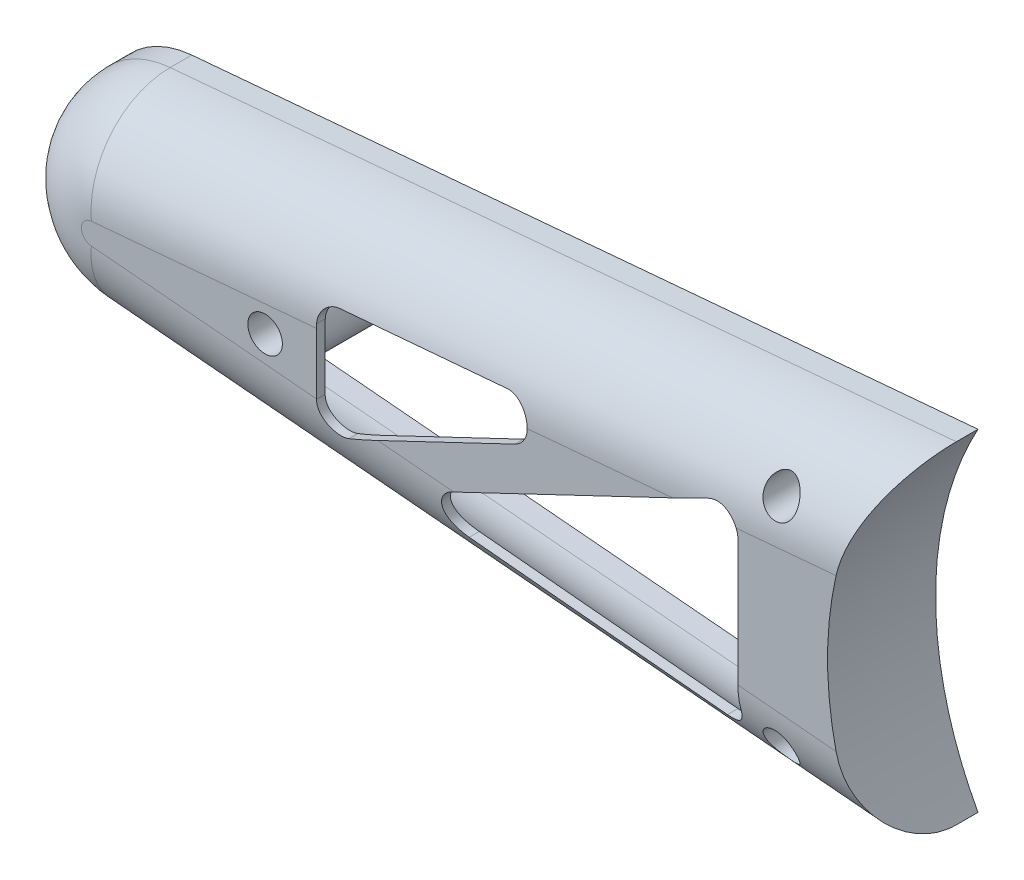
from build123d import *

# Parameters (mm, degrees)
BOSS_EXTRUDE1_DEPTH             = 25
BOSS_EXTRUDE1_DEPTH_BACK        = 25
FILLET1_R                       = 20
SHELL1_T                        = 2
CUT_EXTRUDE1_DEPTH              = 154.948043209
BOSS_EXTRUDE2_REACH             = 149.733
SKETCH4_R                       = 7.5
BOSS_EXTRUDE2_DIRECTION_2_REACH = 149.733
CUT_EXTRUDE2_DEPTH              = 148.732867071
CUT_EXTRUDE2_DEPTH_BACK         = 148.732867071
SKETCH5_R                       = 1.75
SKETCH6_R                       = 4
CUT_EXTRUDE3_DEPTH              = 12
CHAMFER1_SIZE                   = 2
SKETCH7_W                       = 361.368008509
SKETCH7_H                       = 191.328530185
CUT_EXTRUDE4_DEPTH              = 148.732867071
CUT_EXTRUDE5_DEPTH              = 148.732867071
BOSS_EXTRUDE3_REACH             = 132.788


with BuildPart() as part:
    # Sketch1 → Boss-Extrude1 (new, two sides: drawn at the far end of the back side and taken through both)
    with BuildSketch(Plane.XY.offset(-BOSS_EXTRUDE1_DEPTH_BACK)):
        with BuildLine():
            Line((-101.96875, 22.41370169), (96.5, 39.846580782))
            ThreePointArc((96.5, 39.846580782), (140, 0), (96.5, -39.846580782))
            Line((96.5, -39.846580782), (-101.96875, -22.41370169))
            ThreePointArc((-101.96875, -22.41370169), (-122.5, 0), (-101.96875, 22.41370169))
        make_face()
    extrude(amount=BOSS_EXTRUDE1_DEPTH + BOSS_EXTRUDE1_DEPTH_BACK)

    # Fillet1
    fillet1_edges = [part.edges().sort_by_distance(p)[0] for p in [
        (-2.734375, -31.130141236, -25),
        (140, 0, -25),
        (-2.734375, 31.130141236, -25),
        (-122.5, 0, -25),
        (-2.734375, 31.130141236, 25),
        (140, 0, 25),
        (-2.734375, -31.130141236, 25),
        (-122.5, 0, 25),
    ]]
    fillet(fillet1_edges, radius=FILLET1_R)

    # Shell1 (no face opened: a closed hollow body)
    add(offset(amount=-SHELL1_T, mode=Mode.PRIVATE), mode=Mode.SUBTRACT)

    # Sketch2 → Cut-Extrude1 (cut, through all)
    with BuildSketch(Plane.XY.offset(25)):
        with BuildLine():
            Line((49.437173226, 13.583043514), (49.437173226, -20.924247919))
            ThreePointArc((49.437173226, -20.924247919), (47.779211905, -24.643223244), (43.904862239, -25.895831672))
            Line((43.904862239, -25.895831672), (-15.19932205, -19.567504869))
            ThreePointArc((-15.19932205, -19.567504869), (-19.595683588, -15.437459669), (-16.818802271, -10.082630233))
            Line((-16.818802271, -10.082630233), (42.285382017, 18.096334397))
            ThreePointArc((42.285382017, 18.096334397), (47.105603847, 17.811456695), (49.437173226, 13.583043514))
        make_face()
        with BuildLine():
            Line((-2.180462074, 6.820738981), (-40.945374431, -11.661118224))
            ThreePointArc((-40.945374431, -11.661118224), (-45.765596261, -11.376240521), (-48.09716564, -7.147827341))
            Line((-48.09716564, -7.147827341), (-48.09716564, 7.992291845))
            ThreePointArc((-48.09716564, 7.992291845), (-46.781400109, 11.372590113), (-43.526599088, 12.973816402))
            Line((-43.526599088, 12.973816402), (-4.761686731, 16.315554421))
            ThreePointArc((-4.761686731, 16.315554421), (0.492631081, 12.6457047), (-2.180462074, 6.820738981))
        make_face()
    extrude(amount=-CUT_EXTRUDE1_DEPTH, mode=Mode.SUBTRACT)

    # Sketch4 → Boss-Extrude2 (add, up to next)
    with BuildSketch(Plane.XY, mode=Mode.PRIVATE) as boss_extrude2_sk1:
        with Locations((-60, 0)):
            Circle(SKETCH4_R)
    boss_extrude2_tool1 = extrude(boss_extrude2_sk1.sketch, amount=BOSS_EXTRUDE2_REACH, mode=Mode.PRIVATE) - part.part
    # Sketch4 → Boss-Extrude2 (add, up to next)
    with BuildSketch(Plane.XY, mode=Mode.PRIVATE) as boss_extrude2_sk2:
        with Locations((57.5, 25)):
            Circle(SKETCH4_R)
    boss_extrude2_tool2 = extrude(boss_extrude2_sk2.sketch, amount=BOSS_EXTRUDE2_REACH, mode=Mode.PRIVATE) - part.part
    # Sketch4 → Boss-Extrude2 (add, up to next)
    with BuildSketch(Plane.XY, mode=Mode.PRIVATE) as boss_extrude2_sk3:
        with Locations((57.5, -25)):
            Circle(SKETCH4_R)
    boss_extrude2_tool3 = extrude(boss_extrude2_sk3.sketch, amount=BOSS_EXTRUDE2_REACH, mode=Mode.PRIVATE) - part.part
    add(boss_extrude2_tool1.solids().sort_by_distance((-60, 0, 0))[0])
    add(boss_extrude2_tool2.solids().sort_by_distance((57.5, 25, 0))[0])
    add(boss_extrude2_tool3.solids().sort_by_distance((57.5, -25, 0))[0])

    # Sketch4 → Boss-Extrude2 direction 2 (add, up to next)
    with BuildSketch(Plane.XY, mode=Mode.PRIVATE) as boss_extrude2_direction_2_sk1:
        with Locations((-60, 0)):
            Circle(SKETCH4_R)
    boss_extrude2_direction_2_tool1 = extrude(boss_extrude2_direction_2_sk1.sketch, amount=-BOSS_EXTRUDE2_DIRECTION_2_REACH, mode=Mode.PRIVATE) - part.part
    # Sketch4 → Boss-Extrude2 direction 2 (add, up to next)
    with BuildSketch(Plane.XY, mode=Mode.PRIVATE) as boss_extrude2_direction_2_sk2:
        with Locations((57.5, 25)):
            Circle(SKETCH4_R)
    boss_extrude2_direction_2_tool2 = extrude(boss_extrude2_direction_2_sk2.sketch, amount=-BOSS_EXTRUDE2_DIRECTION_2_REACH, mode=Mode.PRIVATE) - part.part
    # Sketch4 → Boss-Extrude2 direction 2 (add, up to next)
    with BuildSketch(Plane.XY, mode=Mode.PRIVATE) as boss_extrude2_direction_2_sk3:
        with Locations((57.5, -25)):
            Circle(SKETCH4_R)
    boss_extrude2_direction_2_tool3 = extrude(boss_extrude2_direction_2_sk3.sketch, amount=-BOSS_EXTRUDE2_DIRECTION_2_REACH, mode=Mode.PRIVATE) - part.part
    add(boss_extrude2_direction_2_tool1.solids().sort_by_distance((-60, 0, 0))[0])
    add(boss_extrude2_direction_2_tool2.solids().sort_by_distance((57.5, 25, 0))[0])
    add(boss_extrude2_direction_2_tool3.solids().sort_by_distance((57.5, -25, 0))[0])

    # Sketch5 → Cut-Extrude2 (cut, two sides: drawn at the far end of the back side and taken through both)
    with BuildSketch(Plane.XY.offset(-CUT_EXTRUDE2_DEPTH_BACK)):
        with Locations((57.5, 25)):
            Circle(SKETCH5_R)
        with Locations((57.5, -25)):
            Circle(SKETCH5_R)
        with Locations((-60, 0)):
            Circle(SKETCH5_R)
    extrude(amount=CUT_EXTRUDE2_DEPTH + CUT_EXTRUDE2_DEPTH_BACK, mode=Mode.SUBTRACT)

    # Sketch6 → Cut-Extrude3 (cut)
    with BuildSketch(Plane.XY.offset(25)):
        with Locations((57.5, 25)):
            Circle(SKETCH6_R)
        with Locations((57.5, -25)):
            Circle(SKETCH6_R)
        with Locations((-60, 0)):
            Circle(SKETCH6_R)
    cut_extrude3 = extrude(amount=-CUT_EXTRUDE3_DEPTH, mode=Mode.SUBTRACT)

    # Mirror1: Cut-Extrude3 across plane
    add(cut_extrude3.mirror(Plane.XY), mode=Mode.SUBTRACT)

    # Chamfer1
    chamfer1_edges = [part.edges().sort_by_distance(p)[0] for p in [
        (53.5, -25, 13),
        (53.5, 25, 13),
        (-64, 0, 13),
        (-64, 0, -13),
        (53.5, -25, -13),
        (53.5, 25, -13),
    ]]
    chamfer(chamfer1_edges, length=CHAMFER1_SIZE)

    # Sketch7 → Cut-Extrude4 (cut, through all)
    with BuildSketch(Plane.XY):
        with Locations((9.022936562, -5.185794685)):
            Rectangle(SKETCH7_W, SKETCH7_H)
    extrude(amount=-CUT_EXTRUDE4_DEPTH, mode=Mode.SUBTRACT)

    # Sketch8 → Cut-Extrude5 (cut, through all)
    with BuildSketch(Plane.XY.offset(25)):
        with BuildLine():
            Line((80, 38.397271986), (96.5, 39.846580782))
            ThreePointArc((96.5, 39.846580782), (140, 0), (96.5, -39.846580782))
            Line((96.5, -39.846580782), (80, -38.397271986))
            ThreePointArc((80, -38.397271986), (70.18297161, 0), (80, 38.397271986))
        make_face()
    extrude(amount=-CUT_EXTRUDE5_DEPTH, mode=Mode.SUBTRACT)

    # Sketch9 → Boss-Extrude3 (add, up to next)
    with BuildSketch(Plane(origin=(0, 0, 0), x_dir=(-1, 0, 0), z_dir=(0, 0, -1)), mode=Mode.PRIVATE) as boss_extrude3_sk1:
        with BuildLine():
            Line((-78.888548804, -36.291945066), (-76.215007948, -37.652893006))
            ThreePointArc((-76.215007948, -37.652893006), (-72.116810166, -28.18997051), (-69.223681577, -18.291893212))
            ThreePointArc((-69.223681577, -18.291893212), (-67.18297161, 0), (-69.223681577, 18.291893212))
            ThreePointArc((-69.223681577, 18.291893212), (-72.116810166, 28.18997051), (-76.215007948, 37.652893006))
            Line((-76.215007948, 37.652893006), (-78.888548804, 36.291945066))
            ThreePointArc((-78.888548804, 36.291945066), (-74.938478652, 27.171055914), (-72.149920975, 17.630740446))
            ThreePointArc((-72.149920975, 17.630740446), (-70.18297161, 0), (-72.149920975, -17.630740446))
            ThreePointArc((-72.149920975, -17.630740446), (-74.938478652, -27.171055914), (-78.888548804, -36.291945066))
        make_face()
    boss_extrude3_tool1 = extrude(boss_extrude3_sk1.sketch, amount=-BOSS_EXTRUDE3_REACH, mode=Mode.PRIVATE) - part.part
    add(boss_extrude3_tool1.solids().sort_by_distance((77.206052, -36.293249, 0))[0])


solid = part.part
